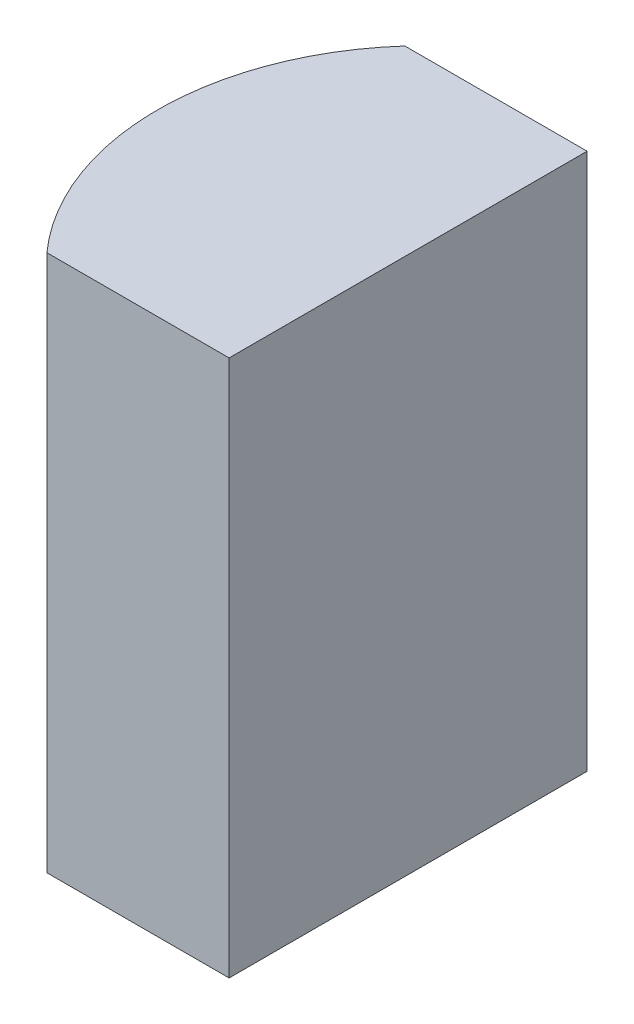
from build123d import *

# Parameters (mm, degrees)
EXTRUDE_1_DEPTH = 6


with BuildPart() as part:
    # 草图1 → 凸台-拉伸1 (new body)
    with BuildSketch(Plane(origin=(0, 0, 0), x_dir=(1, 0, 0), z_dir=(0, 1, 0))):
        with BuildLine():
            Line((0, 0), (0, -4))
            Line((0, -4), (-2.036067977, -4))
            ThreePointArc((-2.036067977, -4), (-2.8, -2), (-2.036067977, 0))
            Line((-2.036067977, 0), (0, 0))
        make_face()
    extrude(amount=EXTRUDE_1_DEPTH)


solid = part.part
